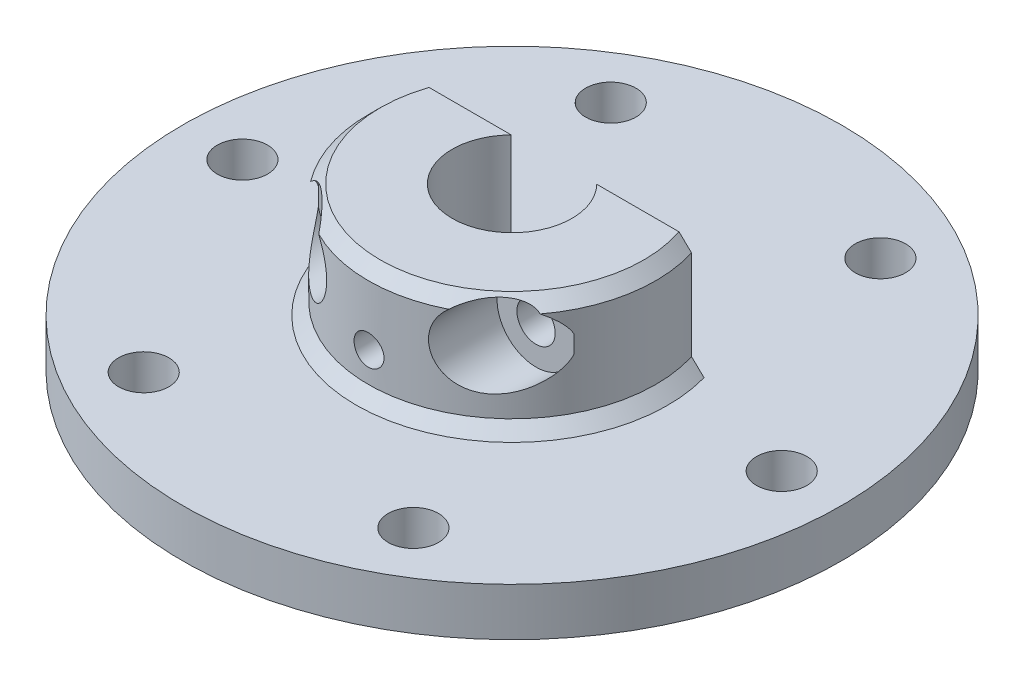
from build123d import *

# Parameters (mm, degrees)
SKETCH_2_R               = 1
CUT_EXTRUDE_2_DEPTH      = 10
CUT_EXTRUDE_4_DEPTH      = 9.5
CHAMFER_1_SIZE           = 1
SKETCH_3_R               = 1.25
SKETCH_3_R_2             = 1.6
CUT_EXTRUDE_3_DEPTH      = 28.5
CUT_EXTRUDE_3_DEPTH_BACK = 28.5
SKETCH_7_R               = 3.25
CUT_EXTRUDE_5_DEPTH      = 23
HOLE_WIZARD_M5_1_D       = 4.2


with BuildPart() as part:
    # 草图1 → 旋转1 (revolve)
    with BuildSketch(Plane.XY):
        Polygon((-10, 2), (-27.5, 2), (-27.5, 6), (-12, 6), (-12, 15.5), (-5, 15.5), (-5, 0), (-10, 0), align=None)
    revolve(axis=Axis((0, 0, 0), (0, 1, 0)))

    # 草图2 → 切除-拉伸2 (cut)
    with BuildSketch(Plane.XZ.offset(-2)):
        with Locations((-11.25, 19.485571585)):
            Circle(SKETCH_2_R)
        with Locations((11.25, 19.485571585)):
            Circle(SKETCH_2_R)
        with Locations((22.5, 0)):
            Circle(SKETCH_2_R)
        with Locations((11.25, -19.485571585)):
            Circle(SKETCH_2_R)
        with Locations((-11.25, -19.485571585)):
            Circle(SKETCH_2_R)
        with Locations((-22.5, 0)):
            Circle(SKETCH_2_R)
    extrude(amount=-CUT_EXTRUDE_2_DEPTH, mode=Mode.SUBTRACT)

    # 草图6 → 切除-拉伸4 (cut)
    with BuildSketch(Plane.XZ.offset(-15.5)):
        with BuildLine():
            Line((11.478240283, -3.5), (-11.478240283, -3.5))
            ThreePointArc((-11.478240283, -3.5), (0, -12), (11.478240283, -3.5))
        make_face()
    extrude(amount=CUT_EXTRUDE_4_DEPTH, mode=Mode.SUBTRACT)

    # 倒角1
    chamfer_1_edges = [part.edges().sort_by_distance(p)[0] for p in [
        (0, 15.5, 12),
        (0, 6, 12),
    ]]
    chamfer(chamfer_1_edges, length=CHAMFER_1_SIZE)

    # 草图3 → 切除-拉伸3 (cut, two sides)
    with BuildSketch(Plane.XY) as cut_extrude_3_sk:
        with Locations((0, 9.5)):
            Circle(SKETCH_3_R)
        with Locations((7.5, 12)):
            Circle(SKETCH_3_R_2)
        with Locations((-7.5, 12)):
            Circle(SKETCH_3_R_2)
    extrude(amount=CUT_EXTRUDE_3_DEPTH, mode=Mode.SUBTRACT)
    extrude(cut_extrude_3_sk.sketch, amount=-CUT_EXTRUDE_3_DEPTH_BACK, mode=Mode.SUBTRACT)

    # 草图7 → 切除-拉伸5 (cut, through all)
    with BuildSketch(Plane(origin=(0, 0, 5.5), x_dir=(-1, 0, 0), z_dir=(0, 0, -1))):
        with Locations((-7.5, 12)):
            Circle(SKETCH_7_R)
        with Locations((7.5, 12)):
            Circle(SKETCH_7_R)
    extrude(amount=-CUT_EXTRUDE_5_DEPTH, mode=Mode.SUBTRACT)

    # M5 螺纹孔1 (through all)
    with Locations(Plane(origin=(0, 6, 0), x_dir=(1, 0, 0), z_dir=(0, 1, 0))):
        with Locations((11.25, 19.485571585), (22.5, 0), (11.25, -19.485571585), (-11.25, -19.485571585), (-22.5, 0), (-11.25, 19.485571585)):
            Hole(HOLE_WIZARD_M5_1_D / 2)


solid = part.part
